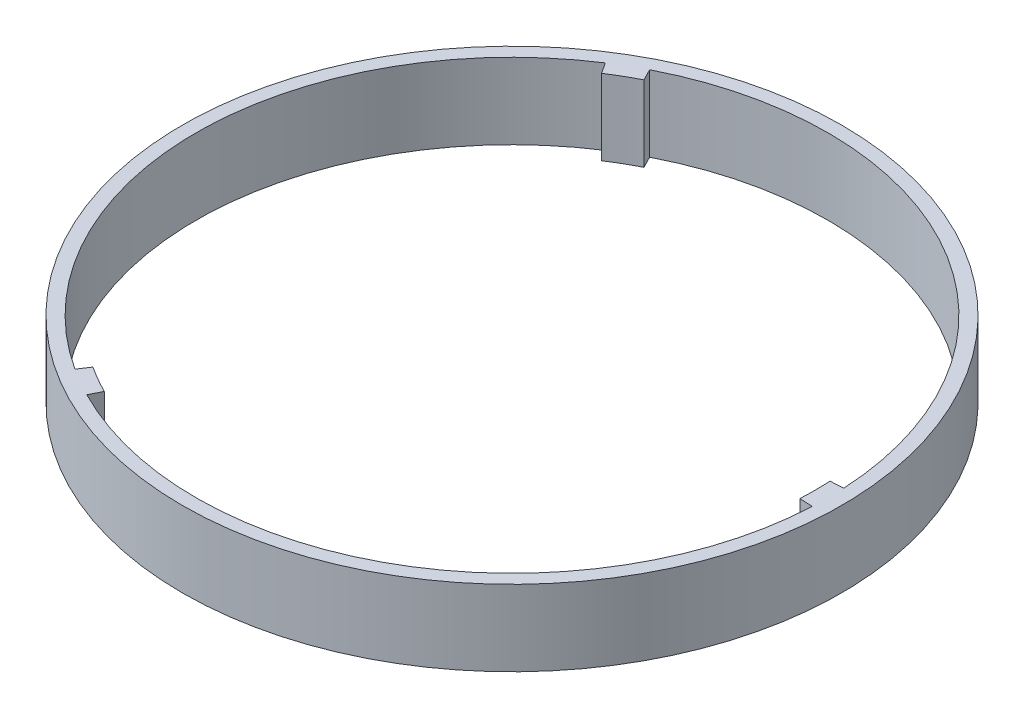
from build123d import *

# Parameters (mm, degrees)
SKETCH1_R           = 110.49
BOSS_EXTRUDE1_DEPTH = 25.4
SKETCH2_R           = 101.6
CUT_EXTRUDE6_DEPTH  = 64.52
CUT_EXTRUDE7_DEPTH  = 64.52
SCALE1_SCALE        = 0.5


with BuildPart() as part:
    # Sketch1 → Boss-Extrude1 (new body)
    with BuildSketch(Plane(origin=(0, 0, 0), x_dir=(1, 0, 0), z_dir=(0, 1, 0))):
        Circle(SKETCH1_R)
    extrude(amount=BOSS_EXTRUDE1_DEPTH)

    # Sketch2 → Cut-Extrude6 (cut)
    with BuildSketch(Plane(origin=(0, 25.4, 0), x_dir=(1, 0, 0), z_dir=(0, 1, 0))):
        Circle(SKETCH2_R)
    extrude(amount=-CUT_EXTRUDE6_DEPTH, mode=Mode.SUBTRACT)

    # Sketch5 → Cut-Extrude7 (cut)
    with BuildSketch(Plane(origin=(0, 25.4, 0), x_dir=(1, 0, 0), z_dir=(0, 1, 0))):
        with BuildLine():
            Line((-46.233713441, -90.471010503), (-55.233336601, -85.275075655))
            Line((-55.233336601, -85.275075655), (-57.601465369, -88.931243691))
            ThreePointArc((-57.601465369, -88.931243691), (-105.956098512, -0.010262293), (-57.618691018, 88.920084135))
            Line((-57.618691018, 88.920084135), (-55.249854064, 85.264374893))
            Line((-55.249854064, 85.264374893), (-46.225266875, 90.475326484))
            Line((-46.225266875, 90.475326484), (-48.207174741, 94.354455224))
            ThreePointArc((-48.207174741, 94.354455224), (52.995520175, 91.750584513), (105.819002137, 5.388293237))
            Line((105.819002137, 5.388293237), (101.468539496, 5.166768105))
            Line((101.468539496, 5.166768105), (101.478542465, -4.966429217))
            Line((101.478542465, -4.966429217), (105.829433983, -5.179364822))
            ThreePointArc((105.829433983, -5.179364822), (53.084989634, -91.698848372), (-48.209389303, -94.353323737))
            Line((-48.209389303, -94.353323737), (-46.233713441, -90.471010503))
        make_face()
    extrude(amount=-CUT_EXTRUDE7_DEPTH, mode=Mode.SUBTRACT)


with BuildPart() as part_1:
    # Scale1: scaled about (-0.039482606, 12.7, -0.004547928)
    add(part.part.scale(SCALE1_SCALE).moved(Location((-0.019741303, 6.35, -0.002273964))))


solid = part_1.part
